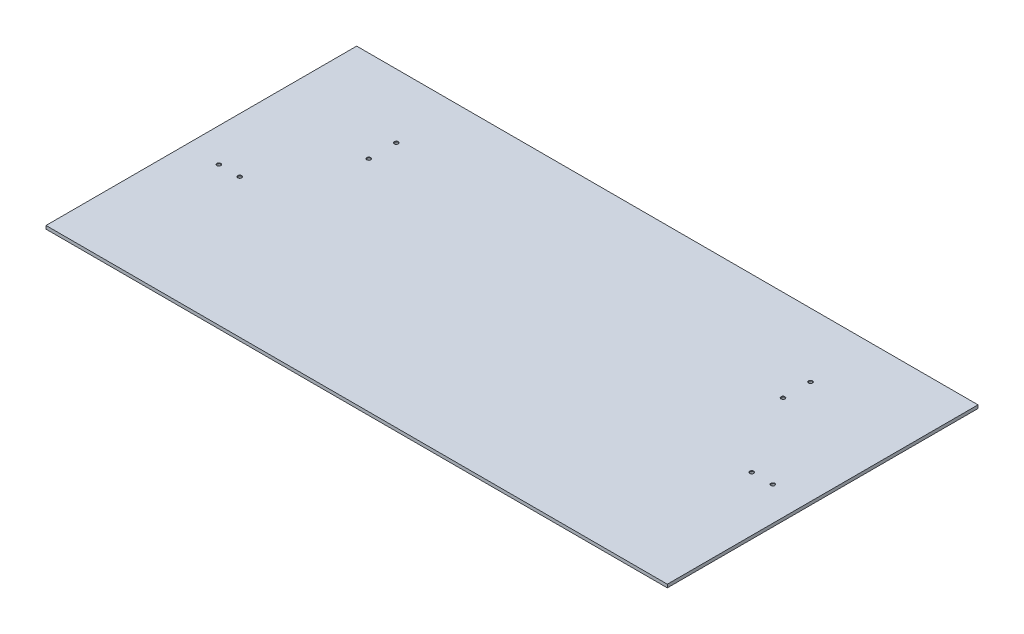
from build123d import *

# Parameters (mm, degrees)
SKETCH1_W                             = 1219.2
SKETCH1_H                             = 609.6
BOSS_EXTRUDE1_DEPTH                   = 6.35
F_1_4_0_25_DIAMETER_HOLE1_D           = 6.35
F_1_4_0_25_DIAMETER_HOLE1_CSINK_D     = 7.7978
F_1_4_0_25_DIAMETER_HOLE1_CSINK_ANGLE = 100


with BuildPart() as part:
    # Sketch1 → Boss-Extrude1 (new body)
    with BuildSketch(Plane(origin=(0, 0, 0), x_dir=(1, 0, 0), z_dir=(0, 1, 0))):
        with Locations((609.6, 304.8)):
            Rectangle(SKETCH1_W, SKETCH1_H)
    extrude(amount=BOSS_EXTRUDE1_DEPTH)

    # 1/4 (0.25) Diameter Hole1 (through all)
    with Locations(Plane(origin=(0, 6.35, 0), x_dir=(1, 0, 0), z_dir=(0, 1, 0))):
        with Locations((66.077719, 273.05), (107.352719, 273.05), (203.2, 484.1875), (203.2, 430.2125), (1016, 484.1875), (1016, 430.2125), (1111.847281, 273.05), (1153.122281, 273.05)):
            CounterSinkHole(F_1_4_0_25_DIAMETER_HOLE1_D / 2, F_1_4_0_25_DIAMETER_HOLE1_CSINK_D / 2, counter_sink_angle=F_1_4_0_25_DIAMETER_HOLE1_CSINK_ANGLE)


solid = part.part
